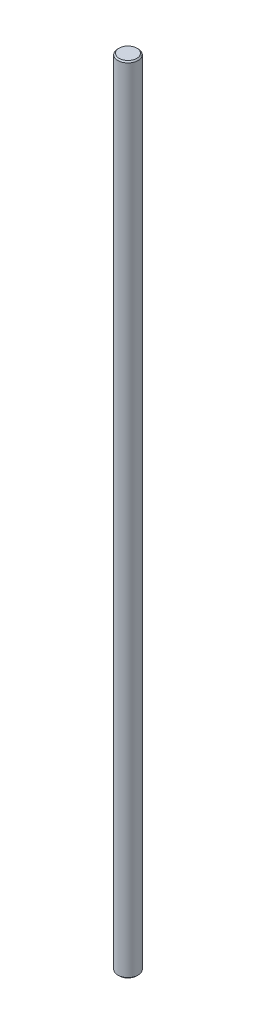
from build123d import *

# Parameters (mm, degrees)
SKETCH1_R           = 4
BOSS_EXTRUDE1_DEPTH = 157
CHAMFER1_SIZE       = 0.5


with BuildPart() as part:
    # Sketch1 → Boss-Extrude1 (new body, symmetric)
    with BuildSketch(Plane(origin=(0, 0, 0), x_dir=(1, 0, 0), z_dir=(0, 1, 0))):
        Circle(SKETCH1_R)
    extrude(amount=BOSS_EXTRUDE1_DEPTH, both=True)

    # Chamfer1
    chamfer1_edges = [part.edges().sort_by_distance(p)[0] for p in [
        (-4, -157, 0),
        (-4, 157, 0),
    ]]
    chamfer(chamfer1_edges, length=CHAMFER1_SIZE)


solid = part.part
